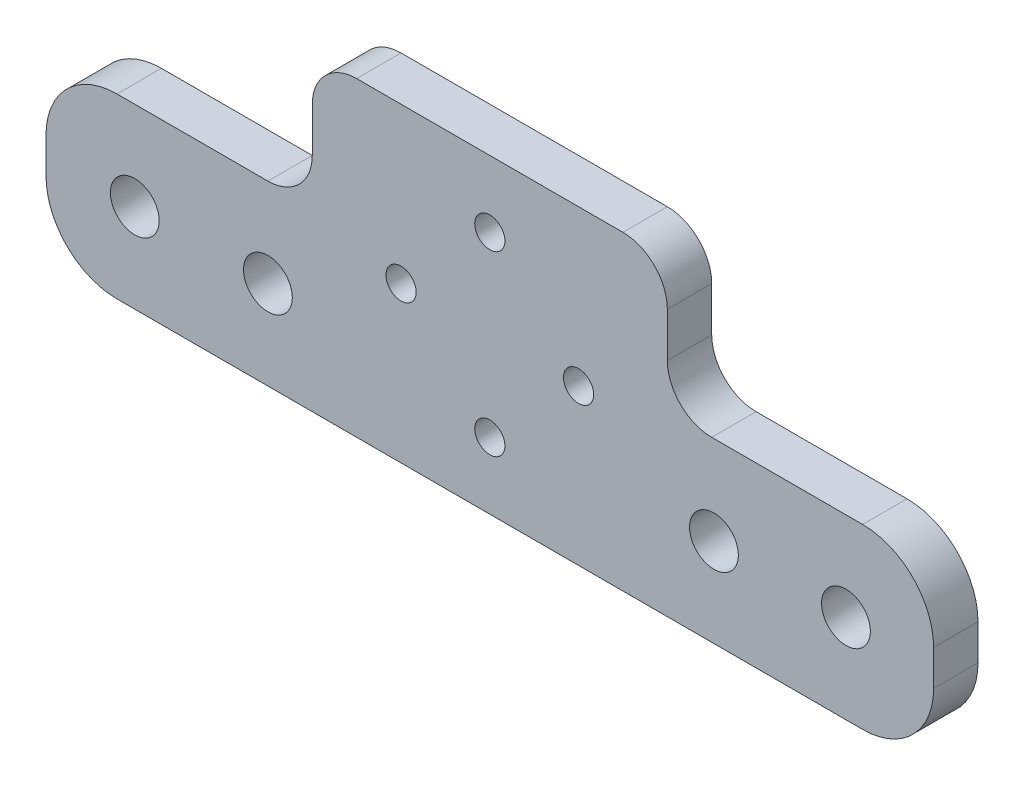
from build123d import *

# Parameters (mm, degrees)
BOSS_EXTRUDE1_DEPTH                             = 5
M5_CLEARANCE_HOLE1_D                            = 5.5
M5_CLEARANCE_HOLE1_DEPTH                        = 5
CSK_FOR_M3_FLAT_HEAD_MACHINE_SCREW1_D           = 3.4
CSK_FOR_M3_FLAT_HEAD_MACHINE_SCREW1_DEPTH       = 5
CSK_FOR_M3_FLAT_HEAD_MACHINE_SCREW1_CSINK_D     = 6.3
CSK_FOR_M3_FLAT_HEAD_MACHINE_SCREW1_CSINK_ANGLE = 90


with BuildPart() as part:
    # Sketch1 → Boss-Extrude1 (new body)
    with BuildSketch(Plane.XY):
        with BuildLine():
            Line((42, 0), (-42, 0))
            ThreePointArc((-42, 0), (-47.656854249, 2.343145751), (-50, 8))
            Line((-50, 8), (-50, 12))
            ThreePointArc((-50, 12), (-47.656854249, 17.656854249), (-42, 20))
            Line((-42, 20), (-25, 20))
            ThreePointArc((-25, 20), (-21.464466094, 21.464466094), (-20, 25))
            Line((-20, 25), (-20, 30))
            ThreePointArc((-20, 30), (-18.535533906, 33.535533906), (-15, 35))
            Line((-15, 35), (15, 35))
            ThreePointArc((15, 35), (18.535533906, 33.535533906), (20, 30))
            Line((20, 30), (20, 25))
            ThreePointArc((20, 25), (21.464466094, 21.464466094), (25, 20))
            Line((25, 20), (42, 20))
            ThreePointArc((42, 20), (47.656854249, 17.656854249), (50, 12))
            Line((50, 12), (50, 8))
            ThreePointArc((50, 8), (47.656854249, 2.343145751), (42, 0))
        make_face()
    extrude(amount=BOSS_EXTRUDE1_DEPTH)

    # M5 Clearance Hole1
    with Locations(Plane.XY.offset(5)):
        with Locations((-40, 10), (-25, 10), (25.25, 10), (40.125, 10)):
            Hole(M5_CLEARANCE_HOLE1_D / 2, depth=M5_CLEARANCE_HOLE1_DEPTH)

    # CSK for M3 Flat Head Machine Screw1
    with Locations(Plane(origin=(0, 0, 0), x_dir=(-1, 0, 0), z_dir=(0, 0, -1))):
        with Locations((-10, 17.5), (0, 7.5), (10, 17.5), (0, 27.5)):
            CounterSinkHole(CSK_FOR_M3_FLAT_HEAD_MACHINE_SCREW1_D / 2, CSK_FOR_M3_FLAT_HEAD_MACHINE_SCREW1_CSINK_D / 2, depth=CSK_FOR_M3_FLAT_HEAD_MACHINE_SCREW1_DEPTH, counter_sink_angle=CSK_FOR_M3_FLAT_HEAD_MACHINE_SCREW1_CSINK_ANGLE)


solid = part.part
